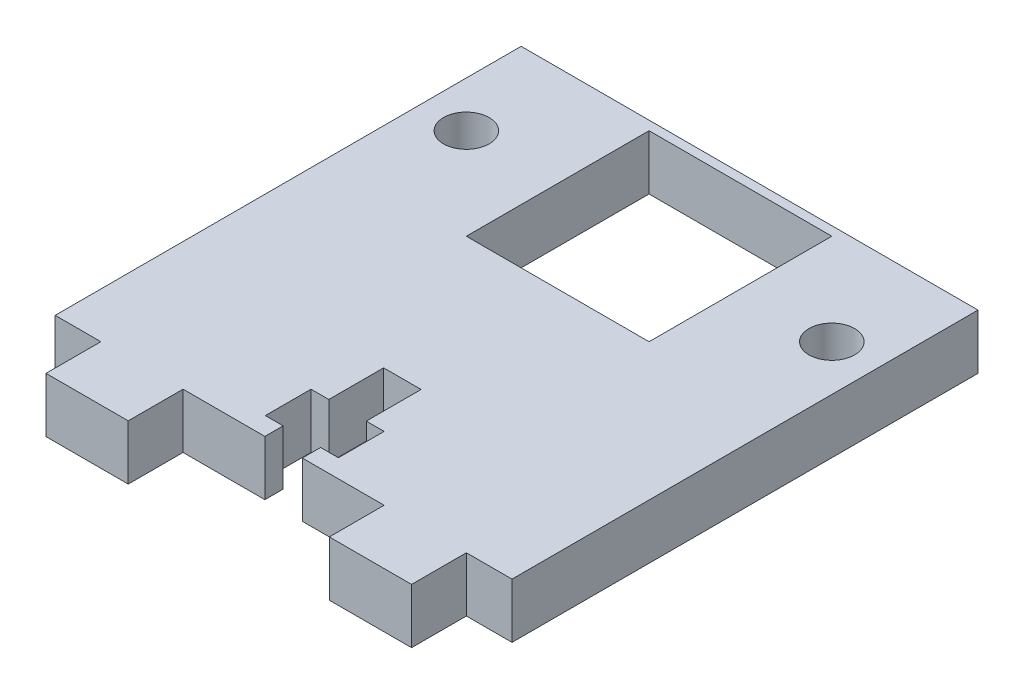
from build123d import *

# Parameters (mm, degrees)
BOSS_EXTRUDE1_DEPTH = 6
SKETCH2_R           = 2.5
SKETCH2_W           = 20
SKETCH2_H           = 20
CUT_EXTRUDE3_DEPTH  = 6


with BuildPart() as part:
    # Sketch1 → Boss-Extrude1 (new body)
    with BuildSketch(Plane(origin=(0, 0, 0), x_dir=(1, 0, 0), z_dir=(0, 1, 0))):
        Polygon((-25, 11), (25, 11), (25, -11), (25, -40), (20.004090827, -40), (20.004090827, -46), (11.004090827, -46), (11.004090827, -40), (2.05, -40), (2.05, -38), (4, -38), (4, -33), (2.05, -33), (2.05, -27), (-2.05, -27), (-2.05, -33), (-4, -33), (-4, -38), (-2.05, -38), (-2.05, -40), (-11.004090827, -40), (-11.004090827, -46), (-20.004090827, -46), (-20.004090827, -40), (-25, -40), (-25, -11), align=None)
    extrude(amount=BOSS_EXTRUDE1_DEPTH)

    # Sketch2 → Cut-Extrude3 (cut)
    with BuildSketch(Plane(origin=(0, 0, 0), x_dir=(1, 0, 0), z_dir=(0, 1, 0))):
        with Locations((-20, 0)):
            Circle(SKETCH2_R)
        with Locations((20, 0)):
            Circle(SKETCH2_R)
        Rectangle(SKETCH2_W, SKETCH2_H)
    extrude(amount=CUT_EXTRUDE3_DEPTH, mode=Mode.SUBTRACT)


solid = part.part
